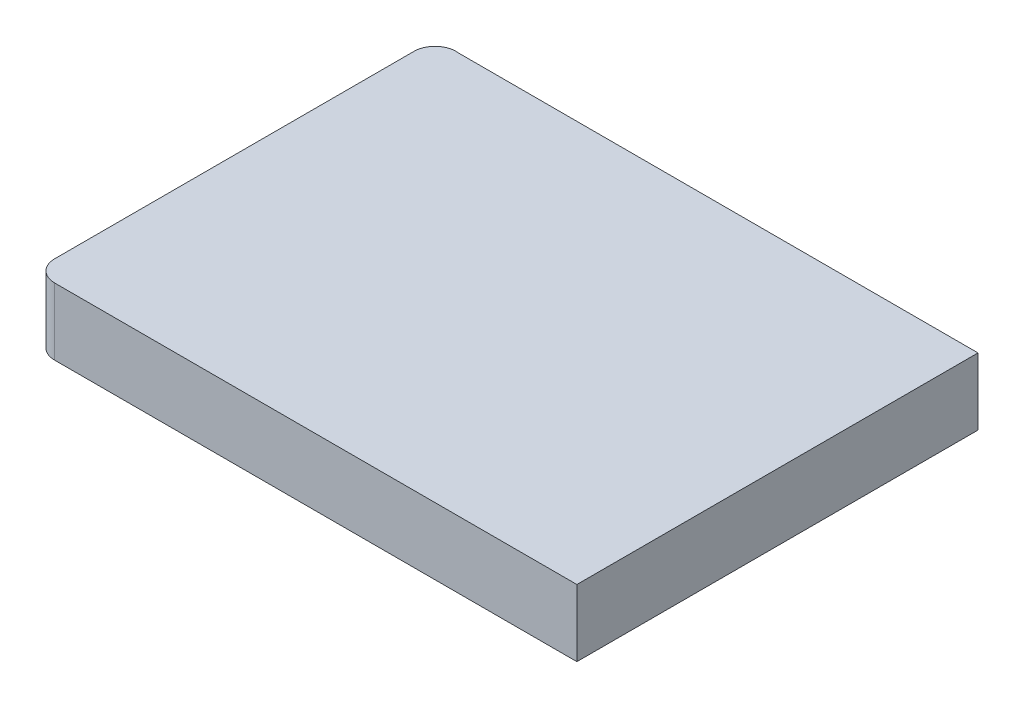
from build123d import *

# Parameters (mm, degrees)
SALIENTE_EXTRUIR1_DEPTH = 8


with BuildPart() as part:
    # Croquis1 → Saliente-Extruir1 (new body)
    with BuildSketch(Plane(origin=(0, 0, 0), x_dir=(1, 0, 0), z_dir=(0, 1, 0))):
        with BuildLine():
            Line((35.275132221, -17.362756007), (35.275132221, 30.637243993))
            Line((35.275132221, 30.637243993), (-26.925575762, 30.637243993))
            ThreePointArc((-26.925575762, 30.637243993), (-28.883446984, 30.025815947), (-29.724867779, 28.155223789))
            Line((-29.724867779, 28.155223789), (-29.724867779, -14.862756007))
            ThreePointArc((-29.724867779, -14.862756007), (-28.992634732, -16.63052296), (-27.224867779, -17.362756007))
            Line((-27.224867779, -17.362756007), (35.275132221, -17.362756007))
        make_face()
    extrude(amount=SALIENTE_EXTRUIR1_DEPTH)


solid = part.part
